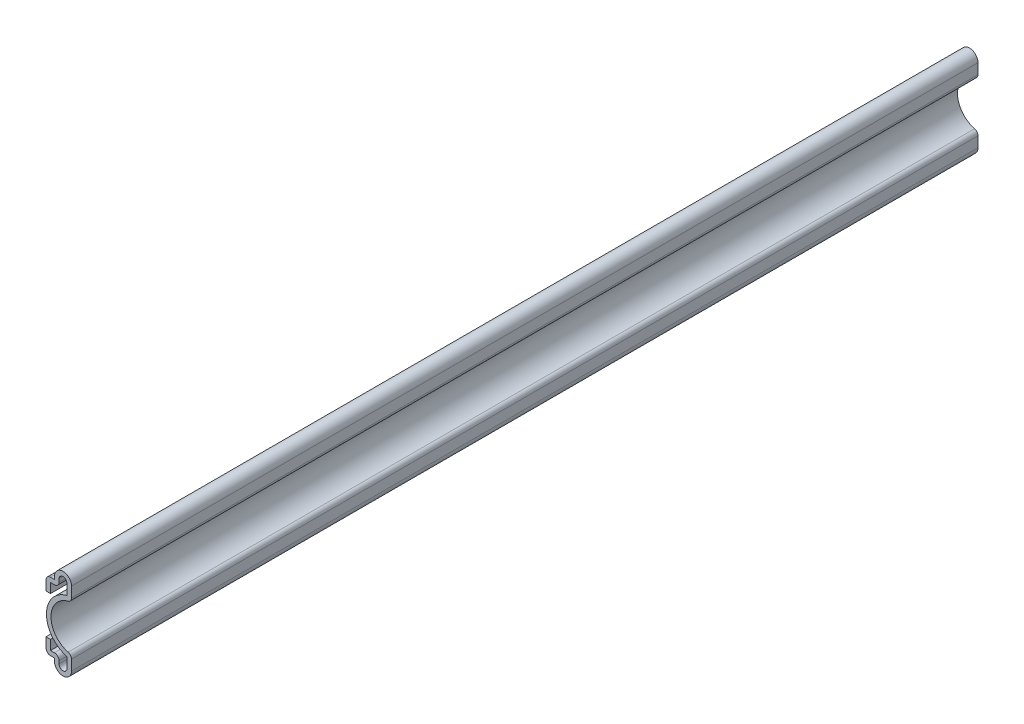
from build123d import *

# Parameters (mm, degrees)
EXTRUDE_THIN1_DEPTH = 254
FILLET1_R           = 1.27


with BuildPart() as part:
    # Sketch1 → Extrude-Thin1 (new body)
    with BuildSketch(Plane.XY):
        with BuildLine():
            Line((-7.14375, 7.14375), (-7.14375, 3.175))
            Line((-7.14375, 3.175), (-4.7625, 3.175))
            Line((-4.7625, 3.175), (-4.7625, 2.38125))
            ThreePointArc((-4.7625, 2.38125), (-2.38125, 0), (0, 2.38125))
            Line((0, 2.38125), (0, 6.35))
            ThreePointArc((0, 6.35), (-5.74675, 12.7), (0, 19.05))
            Line((0, 19.05), (0, 23.01875))
            ThreePointArc((0, 23.01875), (-2.38125, 25.4), (-4.7625, 23.01875))
            Line((-4.7625, 23.01875), (-4.7625, 22.225))
            Line((-4.7625, 22.225), (-7.14375, 22.225))
            Line((-7.14375, 22.225), (-7.14375, 18.25625))
            Line((-7.14375, 18.25625), (-5.87375, 18.25625))
            Line((-5.87375, 18.25625), (-5.87375, 20.955))
            Line((-5.87375, 20.955), (-3.4925, 20.955))
            Line((-3.4925, 20.955), (-3.4925, 23.01875))
            ThreePointArc((-3.4925, 23.01875), (-2.38125, 24.13), (-1.27, 23.01875))
            Line((-1.27, 23.01875), (-1.27, 20.110751986))
            ThreePointArc((-1.27, 20.110751986), (-7.01675, 12.7), (-1.27, 5.289248014))
            Line((-1.27, 5.289248014), (-1.27, 2.38125))
            ThreePointArc((-1.27, 2.38125), (-2.38125, 1.27), (-3.4925, 2.38125))
            Line((-3.4925, 2.38125), (-3.4925, 4.445))
            Line((-3.4925, 4.445), (-5.87375, 4.445))
            Line((-5.87375, 4.445), (-5.87375, 7.14375))
            Line((-5.87375, 7.14375), (-7.14375, 7.14375))
        make_face()
    extrude(amount=-EXTRUDE_THIN1_DEPTH)

    # Fillet1
    fillet1_edges = [part.edges().sort_by_distance(p)[0] for p in [
        (-3.4925, 4.445, -127),
        (-3.4925, 20.955, -127),
        (-7.14375, 22.225, -127),
        (0, 19.05, -127),
        (0, 6.35, -127),
        (-7.14375, 3.175, -127),
    ]]
    fillet(fillet1_edges, radius=FILLET1_R)


solid = part.part
